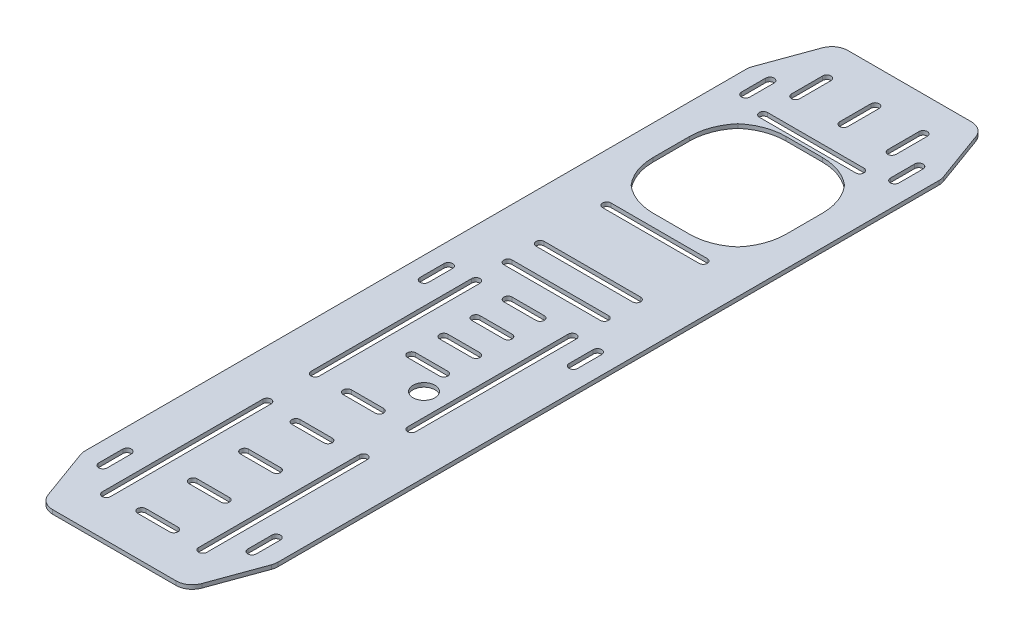
from build123d import *

# Parameters (mm, degrees)
SKETCH1_W           = 152.4
SKETCH1_H           = 660.4
BOSS_EXTRUDE1_DEPTH = 3.18
CUT_EXTRUDE2_DEPTH  = 4.18
CUT_EXTRUDE3_DEPTH  = 4.18
CUT_EXTRUDE4_DEPTH  = 4.18
FILLET1_R           = 12.7
CUT_EXTRUDE6_REACH  = 5.18
SKETCH7_W           = 152.4
SKETCH7_H           = 209.55
SKETCH6_R           = 8.636
CUT_EXTRUDE9_DEPTH  = 4.18
CUT_EXTRUDE10_DEPTH = 4.18
BOSS_EXTRUDE2_DEPTH = 177.8
CUT_EXTRUDE11_DEPTH = 177.8
FILLET2_R           = 12.7
CUT_EXTRUDE12_DEPTH = 177.8
CUT_EXTRUDE13_DEPTH = 177.8
CUT_EXTRUDE15_DEPTH = 177.8


with BuildPart() as part:
    # Sketch1 → Boss-Extrude1 (new body)
    with BuildSketch(Plane(origin=(0, 0, 0), x_dir=(1, 0, 0), z_dir=(0, 1, 0))):
        Rectangle(SKETCH1_W, SKETCH1_H)
    extrude(amount=BOSS_EXTRUDE1_DEPTH)

    # Sketch3 → Cut-Extrude2 (cut, through all)
    with BuildSketch(Plane(origin=(0, 3.18, 0), x_dir=(1, 0, 0), z_dir=(0, 1, 0))):
        with BuildLine():
            Line((-38.1, 54.0639), (38.1, 54.0639))
            ThreePointArc((38.1, 54.0639), (41.3639, 50.8), (38.1, 47.5361))
            Line((38.1, 47.5361), (-38.1, 47.5361))
            ThreePointArc((-38.1, 47.5361), (-41.3639, 50.8), (-38.1, 54.0639))
        make_face()
        with BuildLine():
            Line((-41.3639, 25.4), (-41.3639, -101.6))
            ThreePointArc((-41.3639, -101.6), (-38.1, -104.8639), (-34.8361, -101.6))
            Line((-34.8361, -101.6), (-34.8361, 25.4))
            ThreePointArc((-34.8361, 25.4), (-38.1, 28.6639), (-41.3639, 25.4))
        make_face()
        with BuildLine():
            Line((41.3639, 25.4), (41.3639, -101.6))
            ThreePointArc((41.3639, -101.6), (38.1, -104.8639), (34.8361, -101.6))
            Line((34.8361, -101.6), (34.8361, 25.4))
            ThreePointArc((34.8361, 25.4), (38.1, 28.6639), (41.3639, 25.4))
        make_face()
        with BuildLine():
            Line((-38.1, -130.2639), (38.1, -130.2639))
            ThreePointArc((38.1, -130.2639), (41.3639, -127), (38.1, -123.7361))
            Line((38.1, -123.7361), (-38.1, -123.7361))
            ThreePointArc((-38.1, -123.7361), (-41.3639, -127), (-38.1, -130.2639))
        make_face()
        with BuildLine():
            Line((41.3639, -279.4), (41.3639, -152.4))
            ThreePointArc((41.3639, -152.4), (38.1, -149.1361), (34.8361, -152.4))
            Line((34.8361, -152.4), (34.8361, -279.4))
            ThreePointArc((34.8361, -279.4), (38.1, -282.6639), (41.3639, -279.4))
        make_face()
        with BuildLine():
            Line((-41.3639, -279.4), (-41.3639, -152.4))
            ThreePointArc((-41.3639, -152.4), (-38.1, -149.1361), (-34.8361, -152.4))
            Line((-34.8361, -152.4), (-34.8361, -279.4))
            ThreePointArc((-34.8361, -279.4), (-38.1, -282.6639), (-41.3639, -279.4))
        make_face()
        with BuildLine():
            Line((-38.1, -301.5361), (38.1, -301.5361))
            ThreePointArc((38.1, -301.5361), (41.3639, -304.8), (38.1, -308.0639))
            Line((38.1, -308.0639), (-38.1, -308.0639))
            ThreePointArc((-38.1, -308.0639), (-41.3639, -304.8), (-38.1, -301.5361))
        make_face()
        with BuildLine():
            Line((-12.7, -276.1361), (12.7, -276.1361))
            ThreePointArc((12.7, -276.1361), (15.9639, -279.4), (12.7, -282.6639))
            Line((12.7, -282.6639), (-12.7, -282.6639))
            ThreePointArc((-12.7, -282.6639), (-15.9639, -279.4), (-12.7, -276.1361))
        make_face()
        with BuildLine():
            Line((-12.7, -225.3361), (12.7, -225.3361))
            ThreePointArc((12.7, -225.3361), (15.9639, -228.6), (12.7, -231.8639))
            Line((12.7, -231.8639), (-12.7, -231.8639))
            ThreePointArc((-12.7, -231.8639), (-15.9639, -228.6), (-12.7, -225.3361))
        make_face()
        with BuildLine():
            Line((-12.7, -199.9361), (12.7, -199.9361))
            ThreePointArc((12.7, -199.9361), (15.9639, -203.2), (12.7, -206.4639))
            Line((12.7, -206.4639), (-12.7, -206.4639))
            ThreePointArc((-12.7, -206.4639), (-15.9639, -203.2), (-12.7, -199.9361))
        make_face()
        with BuildLine():
            Line((-12.7, -174.5361), (12.7, -174.5361))
            ThreePointArc((12.7, -174.5361), (15.9639, -177.8), (12.7, -181.0639))
            Line((12.7, -181.0639), (-12.7, -181.0639))
            ThreePointArc((-12.7, -181.0639), (-15.9639, -177.8), (-12.7, -174.5361))
        make_face()
        with BuildLine():
            Line((-12.7, -149.1361), (12.7, -149.1361))
            ThreePointArc((12.7, -149.1361), (15.9639, -152.4), (12.7, -155.6639))
            Line((12.7, -155.6639), (-12.7, -155.6639))
            ThreePointArc((-12.7, -155.6639), (-15.9639, -152.4), (-12.7, -149.1361))
        make_face()
        with BuildLine():
            Line((-12.7, 22.1361), (12.7, 22.1361))
            ThreePointArc((12.7, 22.1361), (15.9639, 25.4), (12.7, 28.6639))
            Line((12.7, 28.6639), (-12.7, 28.6639))
            ThreePointArc((-12.7, 28.6639), (-15.9639, 25.4), (-12.7, 22.1361))
        make_face()
        with BuildLine():
            Line((-12.7, -3.2639), (12.7, -3.2639))
            ThreePointArc((12.7, -3.2639), (15.9639, 0), (12.7, 3.2639))
            Line((12.7, 3.2639), (-12.7, 3.2639))
            ThreePointArc((-12.7, 3.2639), (-15.9639, 0), (-12.7, -3.2639))
        make_face()
        with BuildLine():
            Line((-12.7, -28.6639), (12.7, -28.6639))
            ThreePointArc((12.7, -28.6639), (15.9639, -25.4), (12.7, -22.1361))
            Line((12.7, -22.1361), (-12.7, -22.1361))
            ThreePointArc((-12.7, -22.1361), (-15.9639, -25.4), (-12.7, -28.6639))
        make_face()
        with BuildLine():
            Line((-12.7, -54.0639), (12.7, -54.0639))
            ThreePointArc((12.7, -54.0639), (15.9639, -50.8), (12.7, -47.5361))
            Line((12.7, -47.5361), (-12.7, -47.5361))
            ThreePointArc((-12.7, -47.5361), (-15.9639, -50.8), (-12.7, -54.0639))
        make_face()
        with BuildLine():
            Line((-12.7, -104.8639), (12.7, -104.8639))
            ThreePointArc((12.7, -104.8639), (15.9639, -101.6), (12.7, -98.3361))
            Line((12.7, -98.3361), (-12.7, -98.3361))
            ThreePointArc((-12.7, -98.3361), (-15.9639, -101.6), (-12.7, -104.8639))
        make_face()
        with BuildLine():
            Line((-38.1, 72.9361), (38.1, 72.9361))
            ThreePointArc((38.1, 72.9361), (41.3639, 76.2), (38.1, 79.4639))
            Line((38.1, 79.4639), (-38.1, 79.4639))
            ThreePointArc((-38.1, 79.4639), (-41.3639, 76.2), (-38.1, 72.9361))
        make_face()
        with BuildLine():
            Line((-38.1, 249.471688), (38.1, 249.471688))
            ThreePointArc((38.1, 249.471688), (41.3639, 252.735588), (38.1, 255.999488))
            Line((38.1, 255.999488), (-38.1, 255.999488))
            ThreePointArc((-38.1, 255.999488), (-41.3639, 252.735588), (-38.1, 249.471688))
        make_face()
        with BuildLine():
            Line((-34.8361, 302.83925906), (-34.8361, 278.135588))
            ThreePointArc((-34.8361, 278.135588), (-38.1, 274.871688), (-41.3639, 278.135588))
            Line((-41.3639, 278.135588), (-41.3639, 302.83925906))
            ThreePointArc((-41.3639, 302.83925906), (-38.1, 306.10315906), (-34.8361, 302.83925906))
        make_face()
        with BuildLine():
            Line((3.2639, 302.83925906), (3.2639, 278.135588))
            ThreePointArc((3.2639, 278.135588), (0, 274.871688), (-3.2639, 278.135588))
            Line((-3.2639, 278.135588), (-3.2639, 302.83925906))
            ThreePointArc((-3.2639, 302.83925906), (0, 306.10315906), (3.2639, 302.83925906))
        make_face()
        with BuildLine():
            Line((41.3639, 302.83925906), (41.3639, 278.135588))
            ThreePointArc((41.3639, 278.135588), (38.1, 274.871688), (34.8361, 278.135588))
            Line((34.8361, 278.135588), (34.8361, 302.83925906))
            ThreePointArc((34.8361, 302.83925906), (38.1, 306.10315906), (41.3639, 302.83925906))
        make_face()
        with BuildLine():
            Line((-38.1, 203.751688), (38.1, 203.751688))
            ThreePointArc((38.1, 203.751688), (41.3639, 207.015588), (38.1, 210.279488))
            Line((38.1, 210.279488), (-38.1, 210.279488))
            ThreePointArc((-38.1, 210.279488), (-41.3639, 207.015588), (-38.1, 203.751688))
        make_face()
    extrude(amount=-CUT_EXTRUDE2_DEPTH, mode=Mode.SUBTRACT)

    # Sketch4 → Cut-Extrude3 (cut, through all)
    with BuildSketch(Plane(origin=(0, 3.18, 0), x_dir=(1, 0, 0), z_dir=(0, 1, 0))):
        with BuildLine():
            Line((-14.361406616, 141.819985902), (14.361406616, 141.819985902))
            ThreePointArc((14.361406616, 141.819985902), (29.204496188, 144.493530178), (42.181875503, 152.178110398))
            ThreePointArc((42.181875503, 152.178110398), (49.866455723, 165.155489713), (52.54, 179.998579285))
            Line((52.54, 179.998579285), (52.54, 208.721392518))
            ThreePointArc((52.54, 208.721392518), (49.866455723, 223.56448209), (42.181875503, 236.541861405))
            ThreePointArc((42.181875503, 236.541861405), (29.204496188, 244.226441625), (14.361406616, 246.899985902))
            Line((14.361406616, 246.899985902), (-14.361406616, 246.899985902))
            ThreePointArc((-14.361406616, 246.899985902), (-29.204496188, 244.226441625), (-42.181875503, 236.541861405))
            ThreePointArc((-42.181875503, 236.541861405), (-49.866455724, 223.56448209), (-52.54, 208.721392518))
            Line((-52.54, 208.721392518), (-52.54, 179.998579285))
            ThreePointArc((-52.54, 179.998579285), (-49.866455724, 165.155489713), (-42.181875503, 152.178110398))
            ThreePointArc((-42.181875503, 152.178110398), (-29.204496188, 144.493530178), (-14.361406616, 141.819985902))
        make_face()
    extrude(amount=-CUT_EXTRUDE3_DEPTH, mode=Mode.SUBTRACT)

    # Sketch5 → Cut-Extrude4 (cut, through all)
    with BuildSketch(Plane.XZ):
        Polygon((76.2, 279.4), (57.710312099, 330.2), (76.2, 330.2), align=None)
        Polygon((-57.710312099, 330.2), (-76.2, 330.2), (-76.2, 279.4), align=None)
        Polygon((-76.2, -279.4), (-57.710312099, -330.2), (-76.2, -330.2), align=None)
        Polygon((57.710312099, -330.2), (76.2, -330.2), (76.2, -279.4), align=None)
    extrude(amount=-CUT_EXTRUDE4_DEPTH, mode=Mode.SUBTRACT)

    # Fillet1
    fillet1_edges = [part.edges().sort_by_distance(p)[0] for p in [
        (57.710312099, 1.59, -330.2),
        (76.2, 1.59, -279.4),
        (-76.2, 1.59, -279.4),
        (-57.710312099, 1.59, -330.2),
        (-57.710312099, 1.59, 330.2),
        (-76.2, 1.59, 279.4),
        (76.2, 1.59, 279.4),
        (57.710312099, 1.59, 330.2),
    ]]
    fillet(fillet1_edges, radius=FILLET1_R)

    # Sketch7 → Cut-Extrude6 (cut, up to next)
    with BuildSketch(Plane.XZ, mode=Mode.PRIVATE) as cut_extrude6_sk1:
        with Locations((0, 225.425)):
            Rectangle(SKETCH7_W, SKETCH7_H)
    cut_extrude6_tool1 = extrude(cut_extrude6_sk1.sketch, amount=-CUT_EXTRUDE6_REACH, mode=Mode.PRIVATE) & part.part
    add(cut_extrude6_tool1.solids().sort_by_distance((0, 0, 225.425))[0], mode=Mode.SUBTRACT)

    # Sketch6 → Cut-Extrude9 (cut, through all)
    with BuildSketch(Plane(origin=(0, 3.18, 0), x_dir=(1, 0, 0), z_dir=(0, 1, 0))):
        with Locations((17.106, -70.8034)):
            Circle(SKETCH6_R)
    extrude(amount=-CUT_EXTRUDE9_DEPTH, mode=Mode.SUBTRACT)

    # Sketch10 → Cut-Extrude10 (cut, through all)
    with BuildSketch(Plane.XZ):
        with BuildLine():
            Line((-38.1, -125.640185902), (38.1, -125.640185902))
            ThreePointArc((38.1, -125.640185902), (41.3639, -128.904085902), (38.1, -132.167985902))
            Line((38.1, -132.167985902), (-38.1, -132.167985902))
            ThreePointArc((-38.1, -132.167985902), (-41.3639, -128.904085902), (-38.1, -125.640185902))
        make_face()
    extrude(amount=-CUT_EXTRUDE10_DEPTH, mode=Mode.SUBTRACT)

    # Sketch11 → Boss-Extrude2 (add)
    with BuildSketch(Plane.XY.offset(120.65)):
        Polygon((-75.434096284, 3.18), (76.2, 3.18), (76.2, 0), (-76.2, 0), (-76.2, 3.18), align=None)
    extrude(amount=BOSS_EXTRUDE2_DEPTH)

    # Sketch12 → Cut-Extrude11 (cut)
    with BuildSketch(Plane.XZ):
        Polygon((76.2, 298.45), (76.2, 247.65), (57.710312099, 298.45), align=None)
        Polygon((-76.2, 298.45), (-76.2, 247.65), (-57.710312099, 298.45), align=None)
    extrude(amount=-CUT_EXTRUDE11_DEPTH, mode=Mode.SUBTRACT)

    # Fillet2
    fillet2_edges = [part.edges().sort_by_distance(p)[0] for p in [
        (-57.710312099, 1.59, 298.45),
        (57.710312099, 1.59, 298.45),
        (76.2, 1.59, 247.65),
        (-76.2, 1.59, 247.65),
    ]]
    fillet(fillet2_edges, radius=FILLET2_R)

    # Sketch13 → Cut-Extrude12 (cut)
    with BuildSketch(Plane.XZ):
        with BuildLine():
            Line((-55.803799999, 248.285), (-55.803799999, 229.235))
            ThreePointArc((-55.803799999, 229.235), (-59.181999999, 225.8568), (-62.560199999, 229.235))
            Line((-62.560199999, 229.235), (-62.560199999, 248.285))
            ThreePointArc((-62.560199999, 248.285), (-59.181999999, 251.6632), (-55.803799999, 248.285))
        make_face()
        with BuildLine():
            Line((62.052200001, -259.715), (62.052200001, -278.765))
            ThreePointArc((62.052200001, -278.765), (58.674000001, -282.1432), (55.295800001, -278.765))
            Line((55.295800001, -278.765), (55.295800001, -259.715))
            ThreePointArc((55.295800001, -259.715), (58.674000001, -256.3368), (62.052200001, -259.715))
        make_face()
        with BuildLine():
            Line((-62.413985683, -259.715), (-62.413985683, -278.765))
            ThreePointArc((-62.413985683, -278.765), (-59.035785683, -282.1432), (-55.657585683, -278.765))
            Line((-55.657585683, -278.765), (-55.657585683, -259.715))
            ThreePointArc((-55.657585683, -259.715), (-59.035785683, -256.3368), (-62.413985683, -259.715))
        make_face()
        with BuildLine():
            Line((-55.803799999, -5.715), (-55.803799999, -24.765))
            ThreePointArc((-55.803799999, -24.765), (-59.181999999, -28.1432), (-62.560199999, -24.765))
            Line((-62.560199999, -24.765), (-62.560199999, -5.715))
            ThreePointArc((-62.560199999, -5.715), (-59.181999999, -2.3368), (-55.803799999, -5.715))
        make_face()
        with BuildLine():
            Line((62.052200001, -5.715), (62.052200001, -24.765))
            ThreePointArc((62.052200001, -24.765), (58.674000001, -28.1432), (55.295800001, -24.765))
            Line((55.295800001, -24.765), (55.295800001, -5.715))
            ThreePointArc((55.295800001, -5.715), (58.674000001, -2.3368), (62.052200001, -5.715))
        make_face()
        with BuildLine():
            Line((55.295800001, 248.285), (55.295800001, 229.235))
            ThreePointArc((55.295800001, 229.235), (58.674000001, 225.8568), (62.052200001, 229.235))
            Line((62.052200001, 229.235), (62.052200001, 248.285))
            ThreePointArc((62.052200001, 248.285), (58.674000001, 251.6632), (55.295800001, 248.285))
        make_face()
    extrude(amount=-CUT_EXTRUDE12_DEPTH, mode=Mode.SUBTRACT)

    # Sketch15 → Cut-Extrude13 (cut)
    with BuildSketch(Plane(origin=(0, 3.18, 0), x_dir=(1, 0, 0), z_dir=(0, 1, 0))):
        with BuildLine():
            Line((-34.8361, -101.6), (-34.8361, 25.4))
            ThreePointArc((-34.8361, 25.4), (-38.1, 28.6639), (-41.3639, 25.4))
            Line((-41.3639, 25.4), (-41.3639, -101.6))
            ThreePointArc((-41.3639, -101.6), (-38.1, -104.8639), (-34.8361, -101.6))
        make_face()
        with BuildLine():
            Line((34.8361, 25.4), (34.8361, -101.6))
            ThreePointArc((34.8361, -101.6), (38.1, -104.8639), (41.3639, -101.6))
            Line((41.3639, -101.6), (41.3639, 25.4))
            ThreePointArc((41.3639, 25.4), (38.1, 28.6639), (34.8361, 25.4))
        make_face()
        with BuildLine():
            Line((34.8361, -139.7), (34.8361, -266.7))
            ThreePointArc((34.8361, -266.7), (38.1, -269.9639), (41.3639, -266.7))
            Line((41.3639, -266.7), (41.3639, -139.7))
            ThreePointArc((41.3639, -139.7), (38.1, -136.4361), (34.8361, -139.7))
        make_face()
        with BuildLine():
            Line((-41.3639, -139.7), (-41.3639, -266.7))
            ThreePointArc((-41.3639, -266.7), (-38.1, -269.9639), (-34.8361, -266.7))
            Line((-34.8361, -266.7), (-34.8361, -139.7))
            ThreePointArc((-34.8361, -139.7), (-38.1, -136.4361), (-41.3639, -139.7))
        make_face()
    extrude(amount=-CUT_EXTRUDE13_DEPTH, mode=Mode.SUBTRACT)

    # Sketch16 → Cut-Extrude15 (cut)
    with BuildSketch(Plane(origin=(0, 3.18, 0), x_dir=(1, 0, 0), z_dir=(0, 1, 0))):
        with BuildLine():
            Line((12.7, -98.3361), (-12.7, -98.3361))
            ThreePointArc((-12.7, -98.3361), (-15.9639, -101.6), (-12.7, -104.8639))
            Line((-12.7, -104.8639), (12.7, -104.8639))
            ThreePointArc((12.7, -104.8639), (15.9639, -101.6), (12.7, -98.3361))
        make_face()
        with BuildLine():
            Line((-12.7, -145.5039), (12.7, -145.5039))
            ThreePointArc((12.7, -145.5039), (15.9639, -142.24), (12.7, -138.9761))
            Line((12.7, -138.9761), (-12.7, -138.9761))
            ThreePointArc((-12.7, -138.9761), (-15.9639, -142.24), (-12.7, -145.5039))
        make_face()
        with BuildLine():
            Line((-12.7, -186.1439), (12.7, -186.1439))
            ThreePointArc((12.7, -186.1439), (15.9639, -182.88), (12.7, -179.6161))
            Line((12.7, -179.6161), (-12.7, -179.6161))
            ThreePointArc((-12.7, -179.6161), (-15.9639, -182.88), (-12.7, -186.1439))
        make_face()
        with BuildLine():
            Line((-12.7, -226.7839), (12.7, -226.7839))
            ThreePointArc((12.7, -226.7839), (15.9639, -223.52), (12.7, -220.2561))
            Line((12.7, -220.2561), (-12.7, -220.2561))
            ThreePointArc((-12.7, -220.2561), (-15.9639, -223.52), (-12.7, -226.7839))
        make_face()
        with BuildLine():
            Line((-12.7, -267.4239), (12.7, -267.4239))
            ThreePointArc((12.7, -267.4239), (15.9639, -264.16), (12.7, -260.8961))
            Line((12.7, -260.8961), (-12.7, -260.8961))
            ThreePointArc((-12.7, -260.8961), (-15.9639, -264.16), (-12.7, -267.4239))
        make_face()
    extrude(amount=-CUT_EXTRUDE15_DEPTH, mode=Mode.SUBTRACT)


solid = part.part
